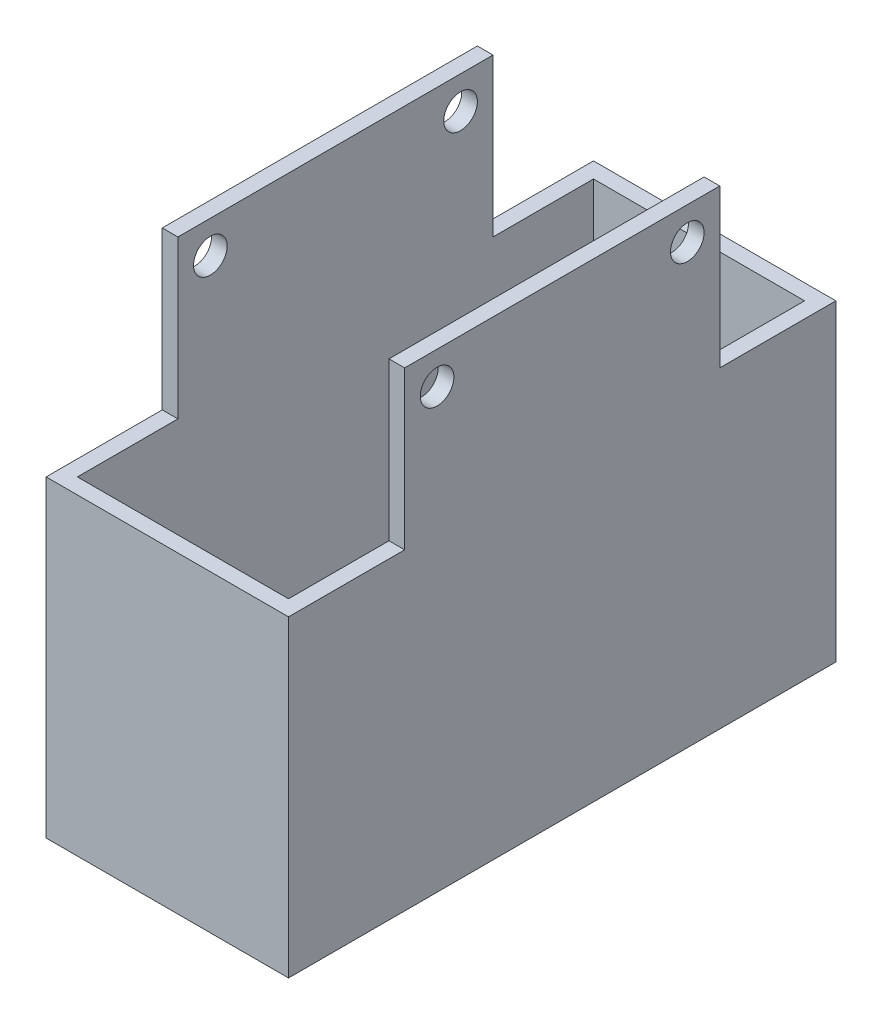
from build123d import *

# Parameters (mm, degrees)
CROQUIS1_W              = 31
CROQUIS1_H              = 70
CROQUIS1_W_2            = 27
CROQUIS1_H_2            = 66
SALIENTE_EXTRUIR1_DEPTH = 40
CROQUIS4_W              = 40.3
CROQUIS4_H              = 20.15
CROQUIS4_R              = 2.15
SALIENTE_EXTRUIR2_DEPTH = 31
CROQUIS5_W              = 27
CROQUIS5_H              = 40.3
CORTAR_EXTRUIR2_DEPTH   = 40
CROQUIS6_W              = 31
CROQUIS6_H              = 70
SALIENTE_EXTRUIR3_DEPTH = 3


with BuildPart() as part:
    # Croquis1 → Saliente-Extruir1 (new body)
    with BuildSketch(Plane(origin=(0, 0, 0), x_dir=(1, 0, 0), z_dir=(0, 1, 0))):
        Rectangle(CROQUIS1_W, CROQUIS1_H)
        Rectangle(CROQUIS1_W_2, CROQUIS1_H_2, mode=Mode.SUBTRACT)
    extrude(amount=SALIENTE_EXTRUIR1_DEPTH)

    # Croquis4 → Saliente-Extruir2 (add, through all)
    with BuildSketch(Plane(origin=(15.5, 0, 0), x_dir=(0, 0, -1), z_dir=(1, 0, 0))):
        with Locations((0, 50.075)):
            Rectangle(CROQUIS4_W, CROQUIS4_H)
        with Locations((-16, 56)):
            Circle(CROQUIS4_R, mode=Mode.SUBTRACT)
        with Locations((16, 56)):
            Circle(CROQUIS4_R, mode=Mode.SUBTRACT)
    extrude(amount=-SALIENTE_EXTRUIR2_DEPTH)

    # Croquis5 → Cortar-Extruir2 (cut)
    with BuildSketch(Plane(origin=(0, 60.15, 0), x_dir=(1, 0, 0), z_dir=(0, 1, 0))):
        Rectangle(CROQUIS5_W, CROQUIS5_H)
    extrude(amount=-CORTAR_EXTRUIR2_DEPTH, mode=Mode.SUBTRACT)

    # Croquis6 → Saliente-Extruir3 (add)
    with BuildSketch(Plane.XZ):
        Rectangle(CROQUIS6_W, CROQUIS6_H)
    extrude(amount=-SALIENTE_EXTRUIR3_DEPTH)


solid = part.part
